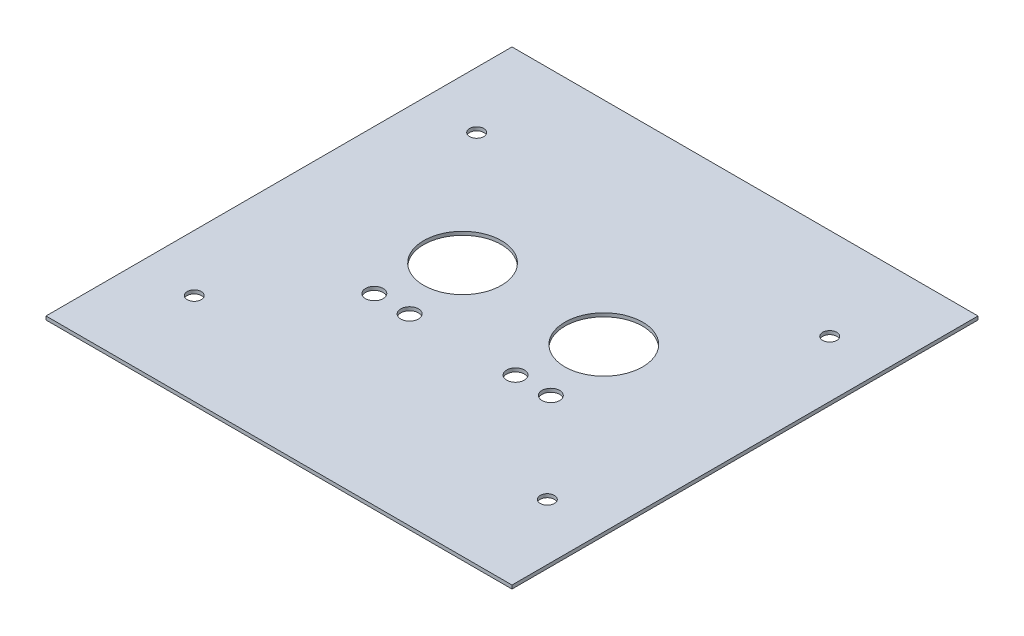
from build123d import *

# Parameters (mm, degrees)
SKETCH1_W           = 132
SKETCH1_H           = 132
SKETCH1_R           = 2.5
SKETCH1_R_2         = 11
BOSS_EXTRUDE1_DEPTH = 1
SKETCH2_R           = 2
CUT_EXTRUDE1_DEPTH  = 2


with BuildPart() as part:
    # Sketch1 → Boss-Extrude1 (new body)
    with BuildSketch(Plane(origin=(0, 0, 0), x_dir=(1, 0, 0), z_dir=(0, 1, 0))):
        with Locations((39.311456102, 43.795094937)):
            Rectangle(SKETCH1_W, SKETCH1_H)
        with Locations((14.311456102, 29.795094937)):
            Circle(SKETCH1_R, mode=Mode.SUBTRACT)
        with Locations((24.311456102, 29.795094937)):
            Circle(SKETCH1_R, mode=Mode.SUBTRACT)
        with Locations((54.311456102, 29.795094937)):
            Circle(SKETCH1_R, mode=Mode.SUBTRACT)
        with Locations((64.311456102, 29.795094937)):
            Circle(SKETCH1_R, mode=Mode.SUBTRACT)
        with Locations((19.311456102, 49.795094937)):
            Circle(SKETCH1_R_2, mode=Mode.SUBTRACT)
        with Locations((59.311456102, 49.795094937)):
            Circle(SKETCH1_R_2, mode=Mode.SUBTRACT)
    extrude(amount=BOSS_EXTRUDE1_DEPTH)

    # Sketch2 → Cut-Extrude1 (cut, through all)
    with BuildSketch(Plane.XZ):
        with Locations((-10.688543898, -3.795094937)):
            Circle(SKETCH2_R)
        with Locations((89.311456102, -3.795094937)):
            Circle(SKETCH2_R)
        with Locations((89.311456102, -83.795094937)):
            Circle(SKETCH2_R)
        with Locations((-10.688543898, -83.795094937)):
            Circle(SKETCH2_R)
    extrude(amount=-CUT_EXTRUDE1_DEPTH, mode=Mode.SUBTRACT)


solid = part.part
